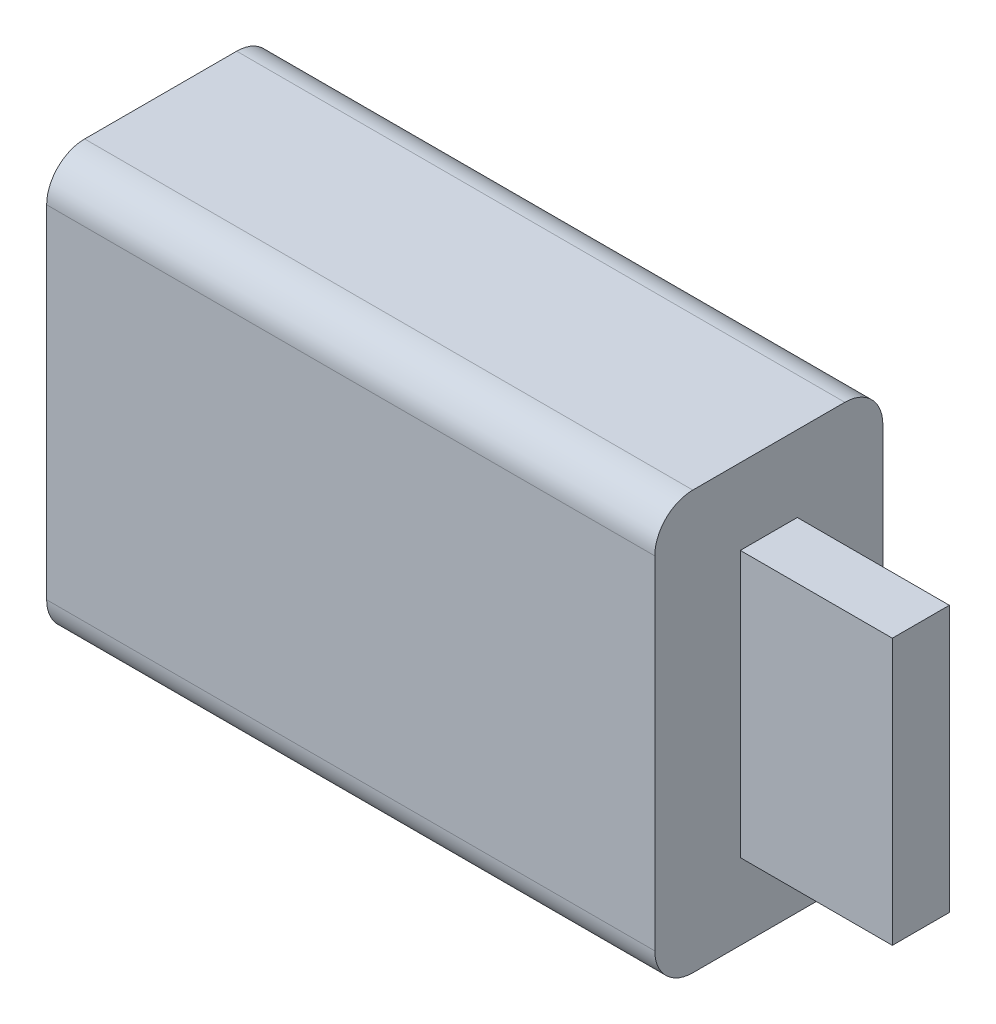
from build123d import *

# Parameters (mm, degrees)
SKICA1_W                = 16
SKICA1_H                = 11
P_IDAT_VYSUNUT_M1_DEPTH = 6
ZAOBLIT1_R              = 1
SKICA2_W                = 1.5
SKICA2_H                = 7
P_IDAT_VYSUNUT_M2_DEPTH = 4


with BuildPart() as part:
    # Skica1 → Přidat vysunutím1 (new body)
    with BuildSketch(Plane.XY):
        Rectangle(SKICA1_W, SKICA1_H)
    extrude(amount=P_IDAT_VYSUNUT_M1_DEPTH)

    # Zaoblit1
    zaoblit1_edges = [part.edges().sort_by_distance(p)[0] for p in [
        (0, -5.5, 6),
        (0, -5.5, 0),
        (0, 5.5, 0),
        (0, 5.5, 6),
    ]]
    fillet(zaoblit1_edges, radius=ZAOBLIT1_R)

    # Skica2 → Přidat vysunutím2 (add)
    with BuildSketch(Plane(origin=(8, 0, 0), x_dir=(0, 0, -1), z_dir=(1, 0, 0))):
        with Locations((-3, 0)):
            Rectangle(SKICA2_W, SKICA2_H)
    extrude(amount=P_IDAT_VYSUNUT_M2_DEPTH)


solid = part.part
